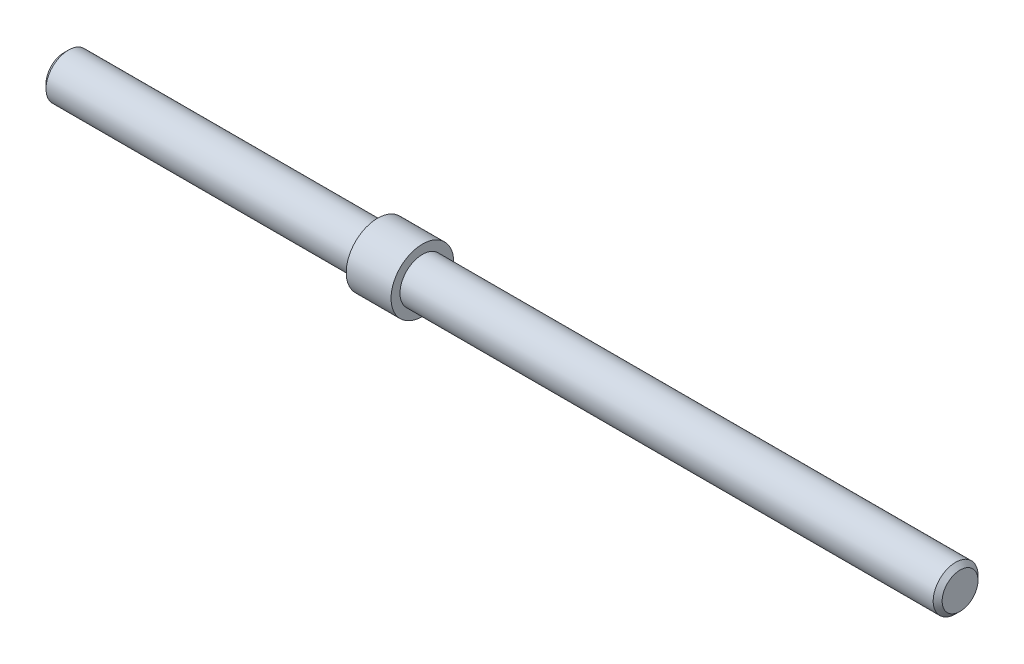
from build123d import *

# Parameters (mm, degrees)
SKETCH1_R           = 5
BOSS_EXTRUDE1_DEPTH = 200
CHAMFER1_SIZE       = 1
BOSS_EXTRUDE2_START = 70
SKETCH2_R           = 7
BOSS_EXTRUDE2_DEPTH = 10


with BuildPart() as part:
    # Sketch1 → Boss-Extrude1 (new body)
    with BuildSketch(Plane(origin=(0, 0, 0), x_dir=(0, 0, -1), z_dir=(1, 0, 0))):
        Circle(SKETCH1_R)
    extrude(amount=BOSS_EXTRUDE1_DEPTH)

    # Chamfer1
    chamfer1_edges = [part.edges().sort_by_distance(p)[0] for p in [
        (0, 0, 5),
        (200, 0, 5),
    ]]
    chamfer(chamfer1_edges, length=CHAMFER1_SIZE)

    # Sketch2 → Boss-Extrude2 (add)
    with BuildSketch(Plane(origin=(0, 0, 0), x_dir=(0, 0, -1), z_dir=(1, 0, 0)).offset(BOSS_EXTRUDE2_START)):
        Circle(SKETCH2_R)
    extrude(amount=BOSS_EXTRUDE2_DEPTH)


solid = part.part
